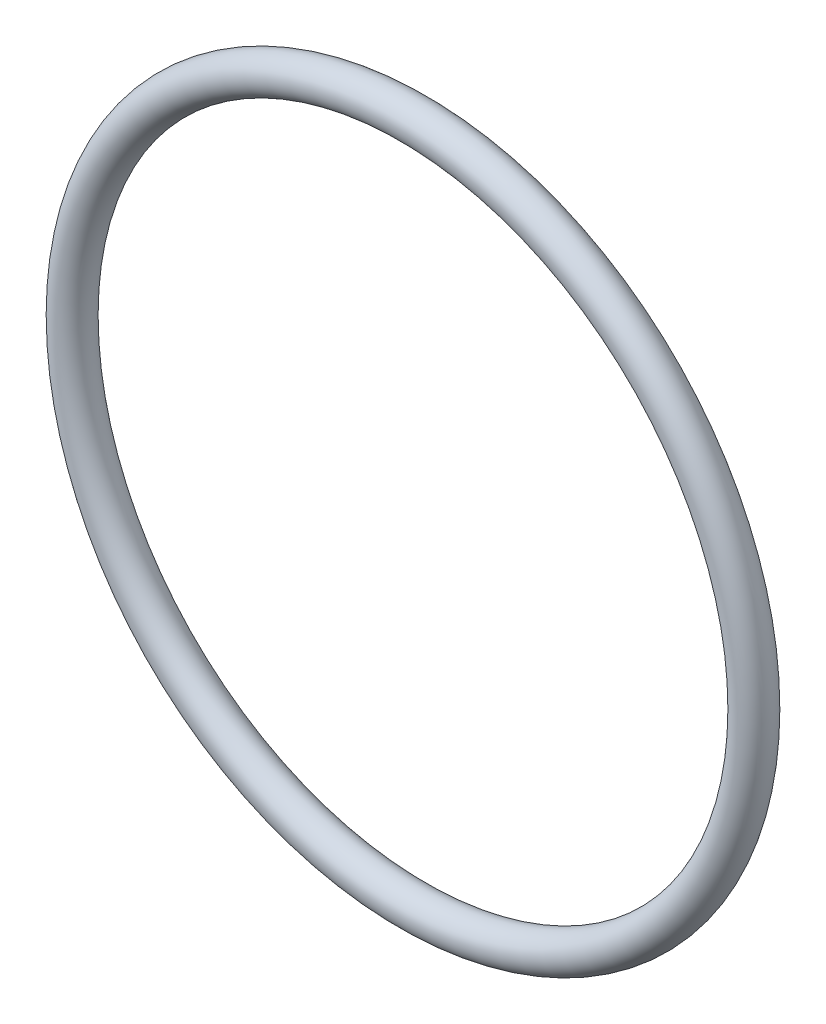
from build123d import *

# Parameters (mm, degrees)
SKETCH2_R = 1.55


with BuildPart() as part:
    # Sweep1: sweep along a path in Sketch1
    with BuildLine(Plane.XY) as sweep1_path:
        CenterArc((0, 0), 27.2, 0, 360)
    # Sketch2 → Sweep1 (sweep)
    with BuildSketch(Plane(origin=(0, 0, 0), x_dir=(1, 0, 0), z_dir=(0, 1, 0))):
        with Locations((-28.75, 0)):
            Circle(SKETCH2_R)
    sweep(path=sweep1_path.line)


solid = part.part
